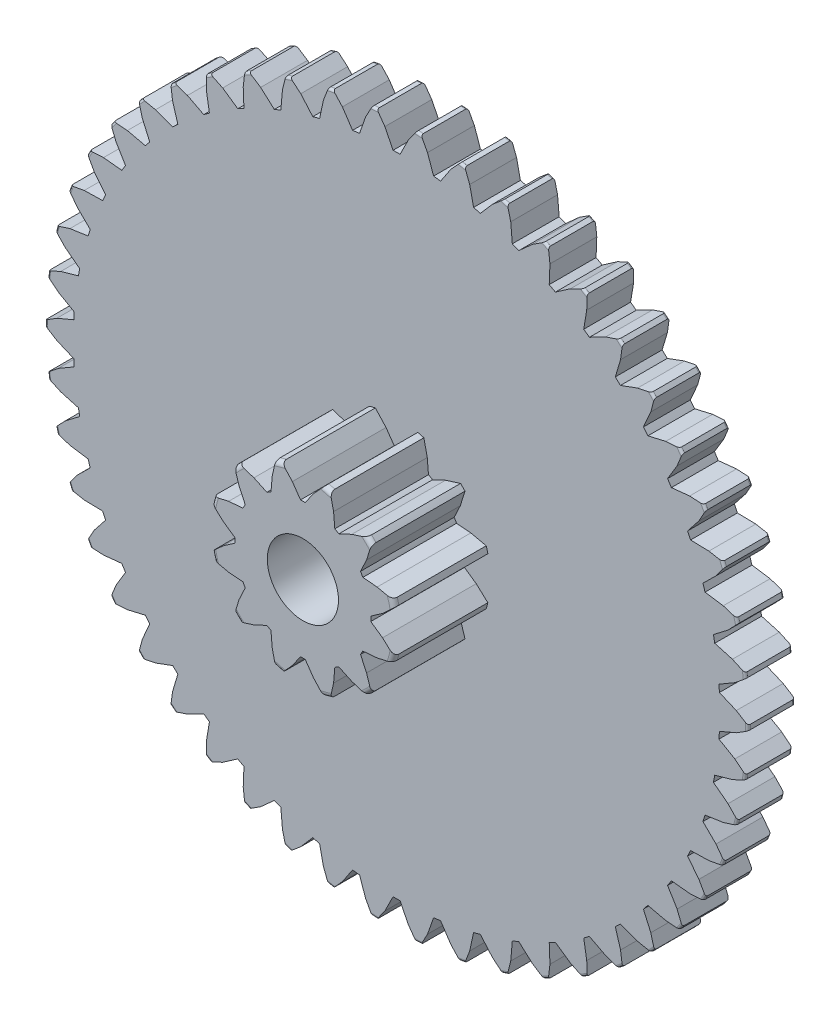
from build123d import *

# Parameters (mm, degrees)
CROQUIS1_R              = 7.5
SALIENTE_EXTRUIR1_DEPTH = 1
CROQUIS3_R              = 2
SALIENTE_EXTRUIR2_DEPTH = 2
CORTAR_EXTRUIR5_DEPTH   = 3
REDONDEO2_R             = 0.05
MATRIZC3_COUNT          = 50
CORTAR_EXTRUIR6_START   = -2
CORTAR_EXTRUIR6_DEPTH   = 2
REDONDEO1_R             = 0.1
MATRIZC4_COUNT          = 12
CROQUIS5_4_R            = 0.76
CORTAR_EXTRUIR8_DEPTH   = 3


with BuildPart() as part:
    # Croquis1 → Saliente-Extruir1 (new body)
    with BuildSketch(Plane.XY):
        Circle(CROQUIS1_R)
    extrude(amount=SALIENTE_EXTRUIR1_DEPTH)

    # Croquis3 → Saliente-Extruir2 (add)
    with BuildSketch(Plane.XY.offset(1)):
        Circle(CROQUIS3_R)
    extrude(amount=SALIENTE_EXTRUIR2_DEPTH)

    # Croquis4 → Cortar-Extruir5 (cut)
    with BuildSketch(Plane.XY.offset(3)):
        with BuildLine():
            Line((0.5, 7.6000000000000005), (-0.5, 7.6000000000000005))
            Line((-0.5, 7.6000000000000005), (-0.25, 7.25))
            Line((-0.25, 7.25), (-0.07500000000000001, 6.899592379264156))
            ThreePointArc((-0.07500000000000011, 6.8995923792641545), (4.2e-16, 6.9), (0.07499999999999943, 6.8995923792641545))
            Line((0.07500000000000001, 6.899592379264156), (0.25, 7.25))
            Line((0.25, 7.25), (0.5, 7.6000000000000005))
        make_face()
    cortar_extruir5 = extrude(amount=-CORTAR_EXTRUIR5_DEPTH, mode=Mode.SUBTRACT)

    # Redondeo2
    redondeo2_edges = [part.edges().sort_by_distance(p)[0] for p in [
        (-7.2e-16, -7.5, 0),
        (2.11e-15, -7.5, 1),
    ]]
    fillet(redondeo2_edges, radius=REDONDEO2_R)

    # MatrizC3: Cortar-Extruir5 ×50 about axis
    matrizc3_axis = Axis((0, 0, 1), (0, 0, -1))
    for i in range(1, MATRIZC3_COUNT):
        add(cortar_extruir5.rotate(matrizc3_axis, i * 360 / MATRIZC3_COUNT), mode=Mode.SUBTRACT)

    # Croquis5 → Cortar-Extruir6 (cut)
    with BuildSketch(Plane.XY.offset(3).offset(CORTAR_EXTRUIR6_START)):
        with BuildLine():
            ThreePointArc((-0.05000000000000001, 1.4491376746189437), (-1e-17, 1.4499999999999997), (0.04999999999999996, 1.449137674618944))
            Line((0.05, 1.4491376746189437), (0.22499999999999998, 1.7))
            Line((0.225, 1.7), (0.4524672880478463, 1.9481461324158322))
            ThreePointArc((0.4524672880478684, 1.9481461324157918), (-6e-17, 2), (-0.4524672880478684, 1.9481461324157916))
            Line((-0.4524672880478463, 1.9481461324158325), (-0.225, 1.7))
            Line((-0.22499999999999998, 1.7), (-0.05, 1.4491376746189437))
        make_face()
    cortar_extruir6 = extrude(amount=CORTAR_EXTRUIR6_DEPTH, mode=Mode.SUBTRACT)

    # Redondeo1
    redondeo1_edges = [part.edges().sort_by_distance(p)[0] for p in [
        (3.3e-16, -2, 3),
    ]]
    fillet(redondeo1_edges, radius=REDONDEO1_R)

    # MatrizC4: Cortar-Extruir6 ×12 about axis
    matrizc4_axis = Axis((0, 0, 3), (0, 0, -1))
    for i in range(1, MATRIZC4_COUNT):
        add(cortar_extruir6.rotate(matrizc4_axis, i * 360 / MATRIZC4_COUNT), mode=Mode.SUBTRACT)

    # Croquis5_4 → Cortar-Extruir8 (cut)
    with BuildSketch(Plane.XY.offset(3)):
        Circle(CROQUIS5_4_R)
    extrude(amount=-CORTAR_EXTRUIR8_DEPTH, mode=Mode.SUBTRACT)


solid = part.part
